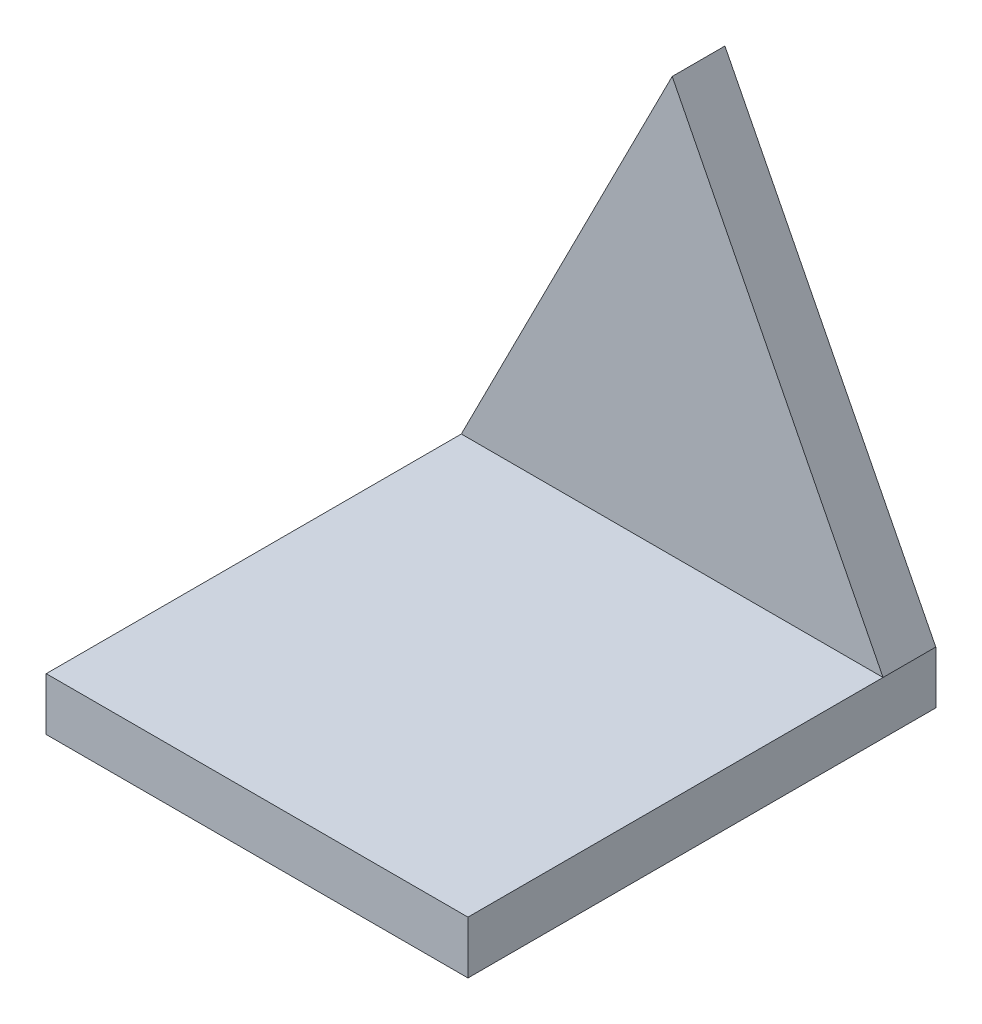
from build123d import *

# Parameters (mm, degrees)
SKETCH2_W               = 25.4
SKETCH2_H               = 28.175
BOSS_EXTRUDE1_DEPTH     = 3.175
SKETCH3_W               = 25.4
SKETCH3_H               = 3.175
BOSS_EXTRUDE2_DEPTH     = 25
CUT_EXTRUDE1_DEPTH      = 26
CUT_EXTRUDE1_DEPTH_BACK = 4.175


with BuildPart() as part:
    # Sketch2 → Boss-Extrude1 (new body)
    with BuildSketch(Plane(origin=(0, 0, 0), x_dir=(1, 0, 0), z_dir=(0, 1, 0))):
        with Locations((12.7, 14.0875)):
            Rectangle(SKETCH2_W, SKETCH2_H)
    extrude(amount=BOSS_EXTRUDE1_DEPTH)

    # Sketch3 → Boss-Extrude2 (add)
    with BuildSketch(Plane(origin=(0, 3.175, 0), x_dir=(1, 0, 0), z_dir=(0, 1, 0))):
        with Locations((12.7, 26.5875)):
            Rectangle(SKETCH3_W, SKETCH3_H)
    extrude(amount=BOSS_EXTRUDE2_DEPTH)

    # Sketch4 → Cut-Extrude1 (cut, two sides)
    with BuildSketch(Plane.XY.offset(-25)) as cut_extrude1_sk:
        Polygon((-36.811931354, -69.289431798), (0, 3.175), (12.7, 28.175), (25.4, 3.175), (62.211931354, -69.289431798), (62.211931354, 93.267784785), (-36.811931354, 93.267784785), align=None)
    extrude(amount=CUT_EXTRUDE1_DEPTH, mode=Mode.SUBTRACT)
    extrude(cut_extrude1_sk.sketch, amount=-CUT_EXTRUDE1_DEPTH_BACK, mode=Mode.SUBTRACT)


solid = part.part
